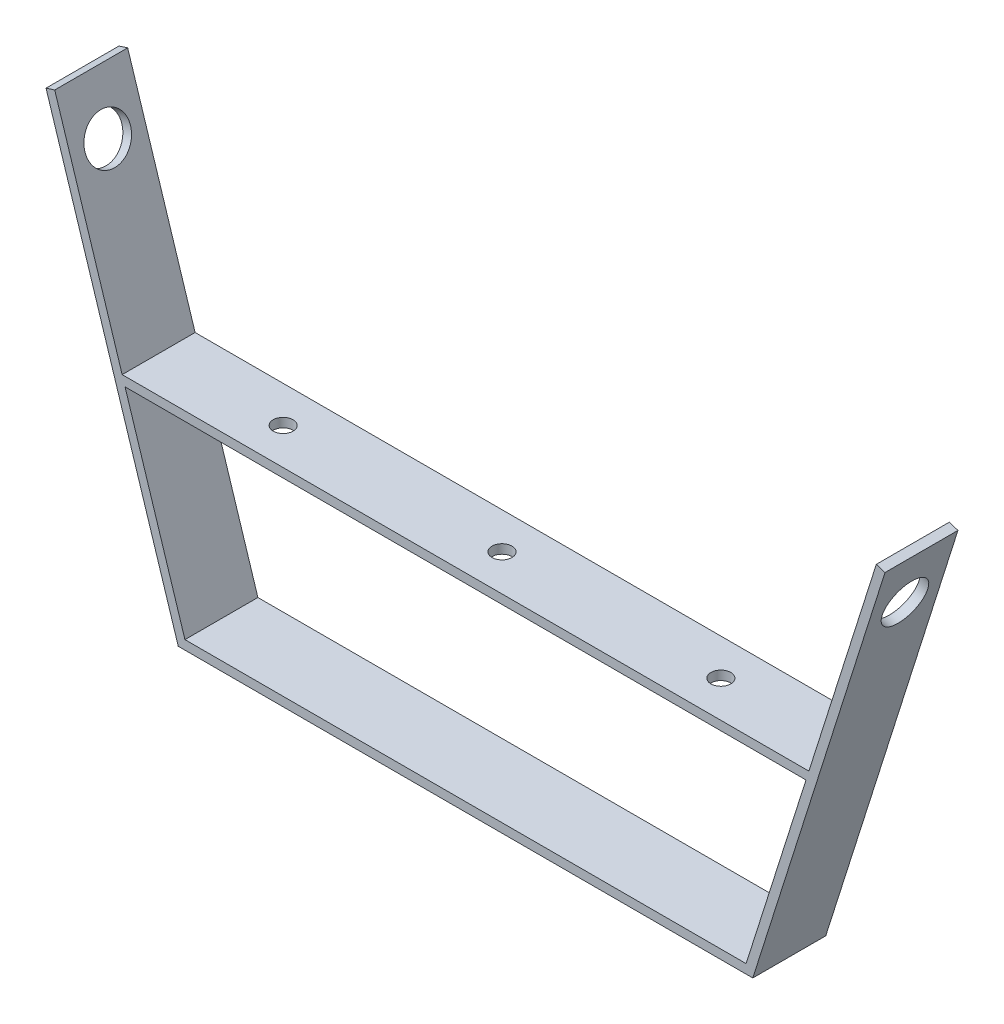
from build123d import *

# Parameters (mm, degrees)
BOSS_EXTRUDE1_DEPTH = 25.4
SKETCH2_R           = 7.9375
CUT_EXTRUDE1_DEPTH  = 25.4
SKETCH3_R           = 7.9375
CUT_EXTRUDE2_DEPTH  = 25.4
BOSS_EXTRUDE2_DEPTH = 25.4
SKETCH6_R           = 3.457615734
CUT_EXTRUDE4_DEPTH  = 3.175


with BuildPart() as part:
    # Sketch1 → Boss-Extrude1 (new body)
    with BuildSketch(Plane.XY):
        Polygon((-95.914729745, -24.450906393), (104.110270255, -24.450906393), (150.147770255, 120.829197523), (147.121101424, 121.788312106), (101.785788593, -21.275906393), (-93.590248082, -21.275906393), (-138.925560913, 121.788312106), (-141.952229745, 120.829197523), align=None)
    extrude(amount=BOSS_EXTRUDE1_DEPTH)

    # Sketch2 → Cut-Extrude1 (cut)
    with BuildSketch(Plane(origin=(-94.203233113, -29.851860148, 0), x_dir=(0, 0, 1), z_dir=(-0.953281522, -0.302083333, 0))):
        with Locations((12.7, 139.015644022)):
            Circle(SKETCH2_R)
    extrude(amount=-CUT_EXTRUDE1_DEPTH, mode=Mode.SUBTRACT)

    # Sketch3 → Cut-Extrude2 (cut)
    with BuildSketch(Plane(origin=(101.650894981, -32.211933717, 0), x_dir=(0, 0, -1), z_dir=(0.953281522, -0.302083333, 0))):
        with Locations((-12.7, 141.491380218)):
            Circle(SKETCH3_R)
    extrude(amount=-CUT_EXTRUDE2_DEPTH, mode=Mode.SUBTRACT)

    # Sketch5 → Boss-Extrude2 (add)
    with BuildSketch(Plane(origin=(0, 0, 0), x_dir=(-1, 0, 0), z_dir=(0, 0, -1))):
        Polygon((-123.641976424, 47.695459109), (115.446435913, 47.695459109), (114.440316985, 44.520459109), (-122.635857495, 44.520459109), align=None)
    extrude(amount=-BOSS_EXTRUDE2_DEPTH)

    # Sketch6 → Cut-Extrude4 (cut)
    with BuildSketch(Plane(origin=(0, 47.695459109, 0), x_dir=(1, 0, 0), z_dir=(0, 1, 0))):
        with Locations((-72.103023576, -12.7)):
            Circle(SKETCH6_R)
        with Locations((4.096976424, -12.7)):
            Circle(SKETCH6_R)
        with Locations((80.296976424, -12.7)):
            Circle(SKETCH6_R)
    extrude(amount=-CUT_EXTRUDE4_DEPTH, mode=Mode.SUBTRACT)


solid = part.part
